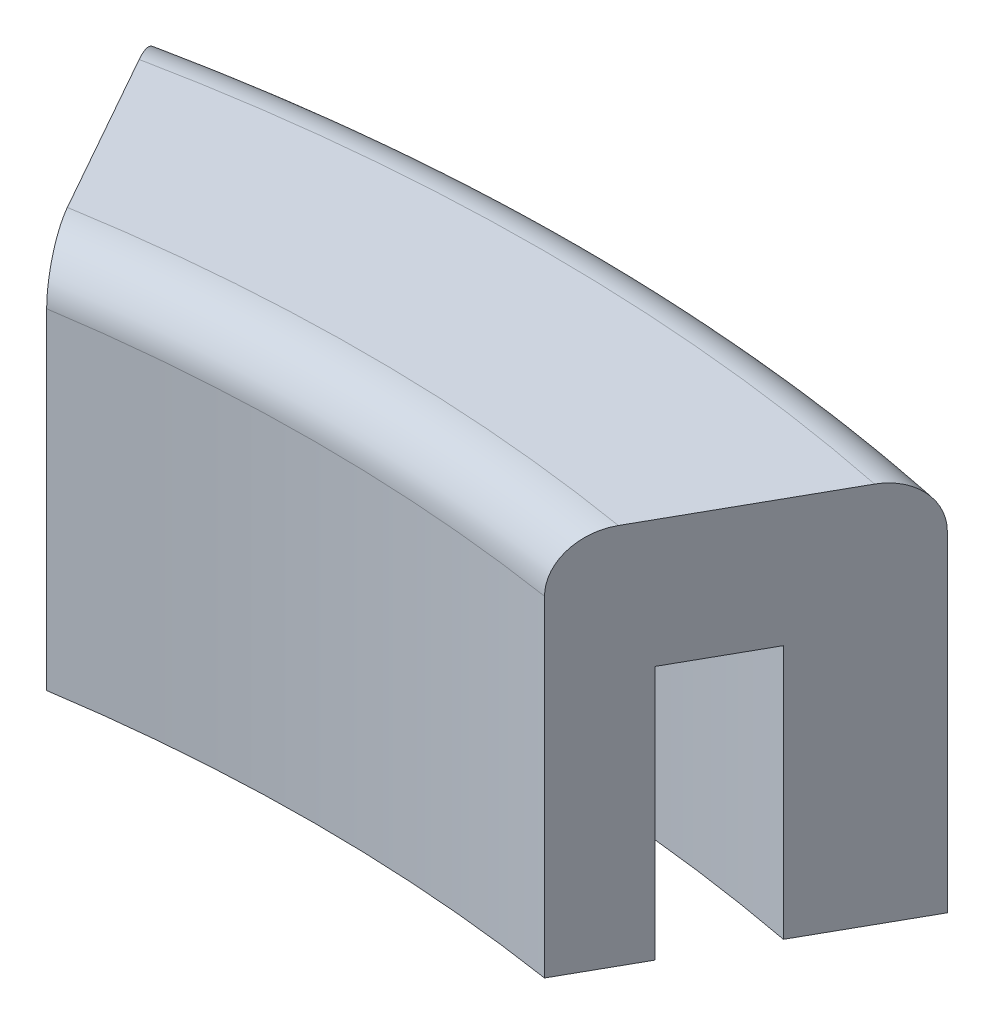
from build123d import *

# Parameters (mm, degrees)
BOSS_EXTRUDE1_DEPTH = 19.05
CUT_EXTRUDE1_DEPTH  = 12.7
FILLET1_R           = 2.54


with BuildPart() as part:
    # Sketch1 → Boss-Extrude1 (new body)
    with BuildSketch(Plane(origin=(0, 0, 0), x_dir=(1, 0, 0), z_dir=(0, 1, 0))):
        with BuildLine():
            Line((12.429156122, 80.324059149), (19.666857156, 93.197517293))
            ThreePointArc((19.666857156, 93.197517293), (0, 95.25), (-19.666857156, 93.197517293))
            Line((-19.666857156, 93.197517293), (-12.429156122, 80.324059149))
            ThreePointArc((-12.429156122, 80.324059149), (0, 81.28), (12.429156122, 80.324059149))
        make_face()
    extrude(amount=BOSS_EXTRUDE1_DEPTH)

    # Sketch3 → Cut-Extrude1 (cut)
    with BuildSketch(Plane.XZ):
        with BuildLine():
            Line((-14.416990913, -83.859754788), (-16.722000277, -87.959598292))
            ThreePointArc((-16.722000277, -87.959598292), (0, -89.535), (16.722000277, -87.959598292))
            Line((16.722000277, -87.959598292), (14.416990913, -83.859754788))
            ThreePointArc((14.416990913, -83.859754788), (0, -85.09), (-14.416990913, -83.859754788))
        make_face()
    extrude(amount=-CUT_EXTRUDE1_DEPTH, mode=Mode.SUBTRACT)

    # Fillet1
    fillet1_edges = [part.edges().sort_by_distance(p)[0] for p in [
        (0, 19.05, -81.28),
        (0, 19.05, -95.25),
    ]]
    fillet(fillet1_edges, radius=FILLET1_R)


solid = part.part
